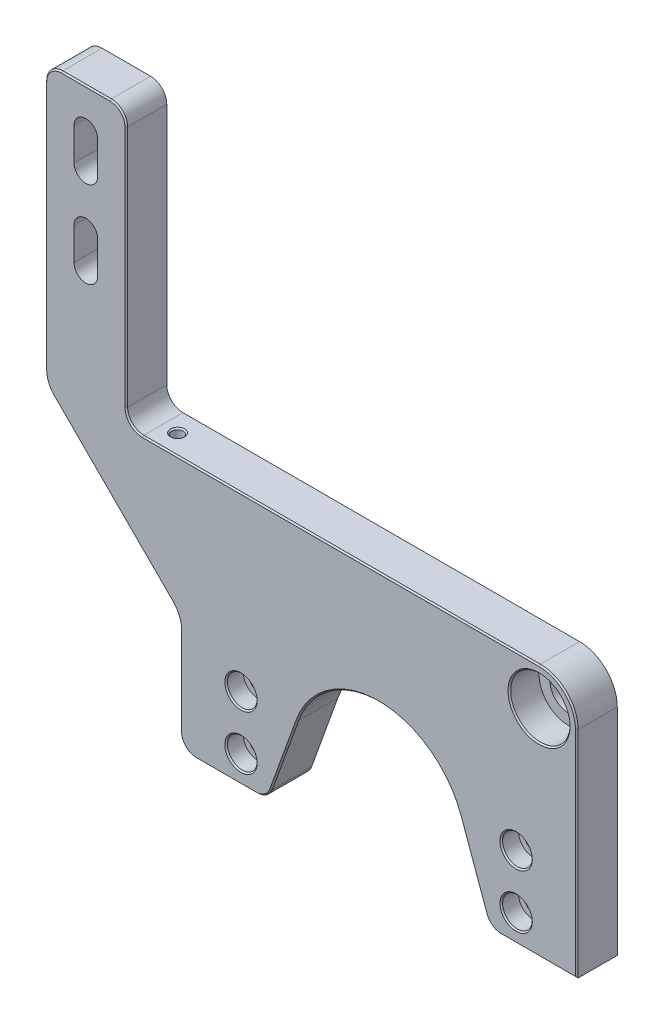
from build123d import *

# Parameters (mm, degrees)
BOSS_EXTRUDE1_DEPTH                                 = 15
FILLET1_R                                           = 6
CBORE_FOR_M6_HEX_SOCKET_HEAD_CAP_SCREW1_D           = 6.6
CBORE_FOR_M6_HEX_SOCKET_HEAD_CAP_SCREW1_CBORE_D     = 11
CBORE_FOR_M6_HEX_SOCKET_HEAD_CAP_SCREW1_CBORE_DEPTH = 6.4
SKETCH6_R                                           = 7
CUT_EXTRUDE3_DEPTH                                  = 16
SKETCH7_R                                           = 11
CUT_EXTRUDE4_DEPTH                                  = 11
TAP_DRILL_FOR_M5_TAP1_D                             = 4.2
TAP_DRILL_FOR_M5_TAP1_DEPTH                         = 10
TAP_DRILL_FOR_M5_TAP1_TIP                           = 1.2618073
FILLET4_R                                           = 14
FILLET5_R                                           = 10
CHAMFER1_SIZE                                       = 0.5


with BuildPart() as part:
    # Sketch1 → Boss-Extrude1 (new body)
    with BuildSketch(Plane.XY):
        with BuildLine():
            Line((-54.083500753, -8.556617627), (-54.083500753, -51.556617627))
            Line((-54.083500753, -51.556617627), (-21.808305332, -51.556617627))
            Line((-21.808305332, -51.556617627), (-10.687429148, -20.70518937))
            ThreePointArc((-10.687429148, -20.70518937), (19.416499247, 0.443382373), (49.520427642, -20.70518937))
            Line((49.520427642, -20.70518937), (60.641303826, -51.556617627))
            Line((60.641303826, -51.556617627), (92.916499247, -51.556617627))
            Line((92.916499247, -51.556617627), (92.916499247, 42.193382373))
            Line((92.916499247, 42.193382373), (-74.083500753, 42.193382373))
            Line((-74.083500753, 42.193382373), (-74.083500753, 144.193382373))
            Line((-74.083500753, 144.193382373), (-104.083500753, 144.193382373))
            Line((-104.083500753, 144.193382373), (-104.083500753, 41.443382373))
            Line((-104.083500753, 41.443382373), (-54.083500753, -8.556617627))
        make_face()
        with BuildLine():
            ThreePointArc((-93.483500753, 97.193382373), (-89.083500753, 101.593382373), (-84.683500753, 97.193382373))
            Line((-84.683500753, 97.193382373), (-84.683500753, 85.193382373))
            ThreePointArc((-84.683500753, 85.193382373), (-89.083500753, 80.793382373), (-93.483500753, 85.193382373))
            Line((-93.483500753, 85.193382373), (-93.483500753, 97.193382373))
        make_face(mode=Mode.SUBTRACT)
        with BuildLine():
            ThreePointArc((-93.483500753, 129.193382373), (-89.083500753, 133.593382373), (-84.683500753, 129.193382373))
            Line((-84.683500753, 129.193382373), (-84.683500753, 117.193382373))
            ThreePointArc((-84.683500753, 117.193382373), (-89.083500753, 112.793382373), (-93.483500753, 117.193382373))
            Line((-93.483500753, 117.193382373), (-93.483500753, 129.193382373))
        make_face(mode=Mode.SUBTRACT)
    extrude(amount=BOSS_EXTRUDE1_DEPTH)

    # Fillet1
    fillet1_edges = [part.edges().sort_by_distance(p)[0] for p in [
        (-21.808305332, -51.556617627, 7.5),
        (-54.083500753, -51.556617627, 7.5),
        (-104.083500753, 144.193382373, 7.5),
        (-74.083500753, 144.193382373, 7.5),
        (-74.083500753, 42.193382373, 7.5),
        (60.641303826, -51.556617627, 7.5),
    ]]
    fillet(fillet1_edges, radius=FILLET1_R)

    # CBORE for M6 Hex Socket Head Cap Screw1 (through all)
    with Locations(Plane.XY.offset(15)):
        with Locations((-31.583500753, -41.556617627), (-31.583500753, -21.556617627), (70.416499247, -41.556617627), (70.416499247, -21.556617627)):
            CounterBoreHole(CBORE_FOR_M6_HEX_SOCKET_HEAD_CAP_SCREW1_D / 2, CBORE_FOR_M6_HEX_SOCKET_HEAD_CAP_SCREW1_CBORE_D / 2, CBORE_FOR_M6_HEX_SOCKET_HEAD_CAP_SCREW1_CBORE_DEPTH)

    # Sketch6 → Cut-Extrude3 (cut, through all)
    with BuildSketch(Plane.XY.offset(15)):
        with Locations((78.916499247, 28.193382373)):
            Circle(SKETCH6_R)
    extrude(amount=-CUT_EXTRUDE3_DEPTH, mode=Mode.SUBTRACT)

    # Sketch7 → Cut-Extrude4 (cut)
    with BuildSketch(Plane.XY.offset(15)):
        with Locations((78.916499247, 28.193382373)):
            Circle(SKETCH7_R)
    extrude(amount=-CUT_EXTRUDE4_DEPTH, mode=Mode.SUBTRACT)

    # Tap Drill for M5 Tap1
    with Locations(Plane(origin=(0, 42.193382373, 0), x_dir=(1, 0, 0), z_dir=(0, 1, 0))):
        with Locations((-62.583500753, -7.5)):
            Hole(TAP_DRILL_FOR_M5_TAP1_D / 2, depth=TAP_DRILL_FOR_M5_TAP1_DEPTH)
            with Locations((0, 0, -(TAP_DRILL_FOR_M5_TAP1_DEPTH + TAP_DRILL_FOR_M5_TAP1_TIP / 2))):  # 118° drill point
                Cone(0, TAP_DRILL_FOR_M5_TAP1_D / 2, TAP_DRILL_FOR_M5_TAP1_TIP, mode=Mode.SUBTRACT)

    # Fillet4
    fillet4_edges = [part.edges().sort_by_distance(p)[0] for p in [
        (92.916499247, 42.193382373, 7.5),
    ]]
    fillet(fillet4_edges, radius=FILLET4_R)

    # Fillet5
    fillet5_edges = [part.edges().sort_by_distance(p)[0] for p in [
        (-54.083500753, -8.556617627, 7.5),
        (-104.083500753, 41.443382373, 7.5),
    ]]
    fillet(fillet5_edges, radius=FILLET5_R)

    # Chamfer1
    chamfer1_edges = [part.edges().sort_by_distance(p)[0] for p in [
        (64.916499247, -41.556617627, 15),
        (-37.083500753, -21.556617627, 15),
        (-37.083500753, -41.556617627, 15),
        (67.916499247, 28.193382373, 15),
        (-60.483500753, 42.193382373, 7.5),
        (88.815994184, 38.09287731, 15),
        (-79.083500753, 16.443382373, 15),
        (-104.083500753, 91.889450185, 15),
        (-103.322296078, 41.758683673, 15),
        (-54.844705428, -8.871918927, 15),
        (19.416499247, 0.443382373, 15),
        (54.366178458, -34.148224897, 15),
        (92.916499247, -11.681617627, 15),
        (-74.083500753, 93.193382373, 15),
        (5.416499247, 42.193382373, 15),
        (-89.083500753, 144.193382373, 15),
        (78.886457547, -51.556617627, 15),
        (-54.083500753, -29.127685439, 15),
        (-37.053459053, -51.556617627, 15),
        (-22.574349131, -50.466192801, 15),
        (61.407347625, -50.466192801, 15),
        (-52.32614144, -49.799258314, 15),
        (-102.32614144, 142.43602306, 15),
        (-75.840860066, 142.43602306, 15),
        (-72.32614144, 43.950741686, 15),
        (-15.533179964, -34.148224897, 15),
        (64.916499247, -21.556617627, 15),
    ]]
    chamfer(chamfer1_edges, length=CHAMFER1_SIZE)


solid = part.part
